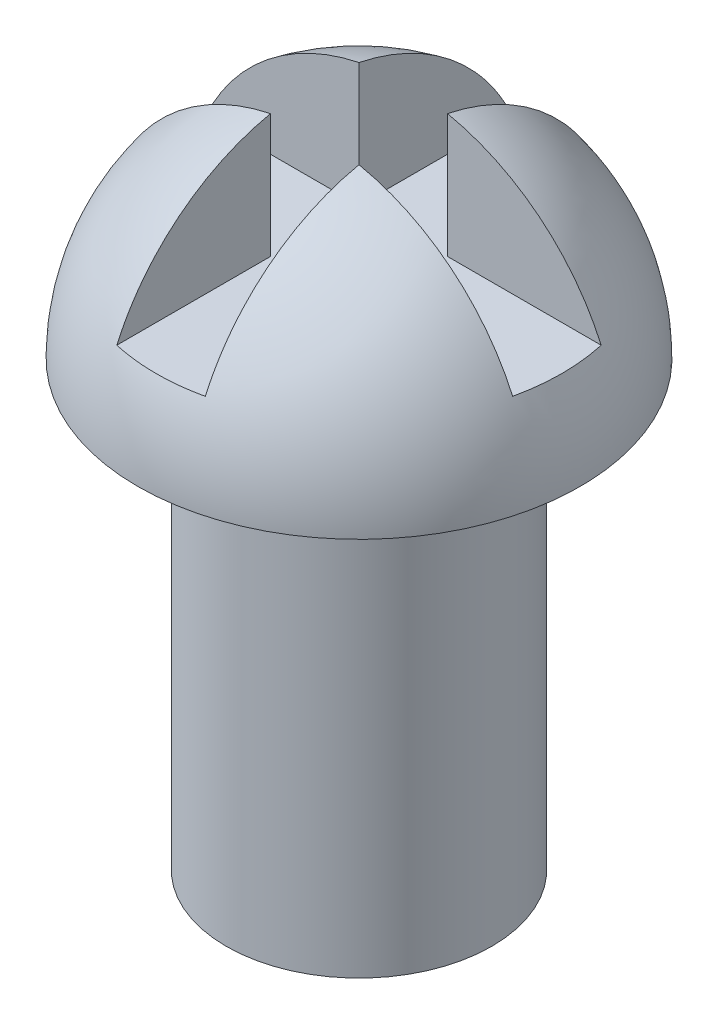
from build123d import *

# Parameters (mm, degrees)
SKETCH1_R           = 1.5
BOSS_EXTRUDE1_DEPTH = 5
REVOLVE1_ANGLE      = 180
CUT_EXTRUDE1_DEPTH  = 3


with BuildPart() as part:
    # Sketch1 → Boss-Extrude1 (new body)
    with BuildSketch(Plane(origin=(0, 0, 0), x_dir=(1, 0, 0), z_dir=(0, 1, 0))):
        Circle(SKETCH1_R)
    extrude(amount=BOSS_EXTRUDE1_DEPTH)

    # Sketch2 → Revolve1 (revolve)
    with BuildSketch(Plane(origin=(0, 5, 0), x_dir=(1, 0, 0), z_dir=(0, 1, 0))):
        with BuildLine():
            Line((0, 2.5), (0, -2.5))
            ThreePointArc((0, -2.5), (2.5, 0), (0, 2.5))
        make_face()
    revolve(axis=Axis((0, 5, -2.5), (0, 0, 1)), revolution_arc=REVOLVE1_ANGLE)

    # Sketch3 → Cut-Extrude1 (cut)
    with BuildSketch(Plane(origin=(0, 9, 0), x_dir=(1, 0, 0), z_dir=(0, 1, 0))):
        Polygon((0.5, 0.5), (5.630024771, 0.5), (5.630024771, -0.5), (0.5, -0.5), (0.5, -4.833323152), (-0.5, -4.833323152), (-0.5, -0.5), (-4.833323152, -0.5), (-4.833323152, 0.5), (-0.5, 0.5), (-0.5, 4.673982829), (0.5, 4.673982829), align=None)
    extrude(amount=-CUT_EXTRUDE1_DEPTH, mode=Mode.SUBTRACT)


solid = part.part
